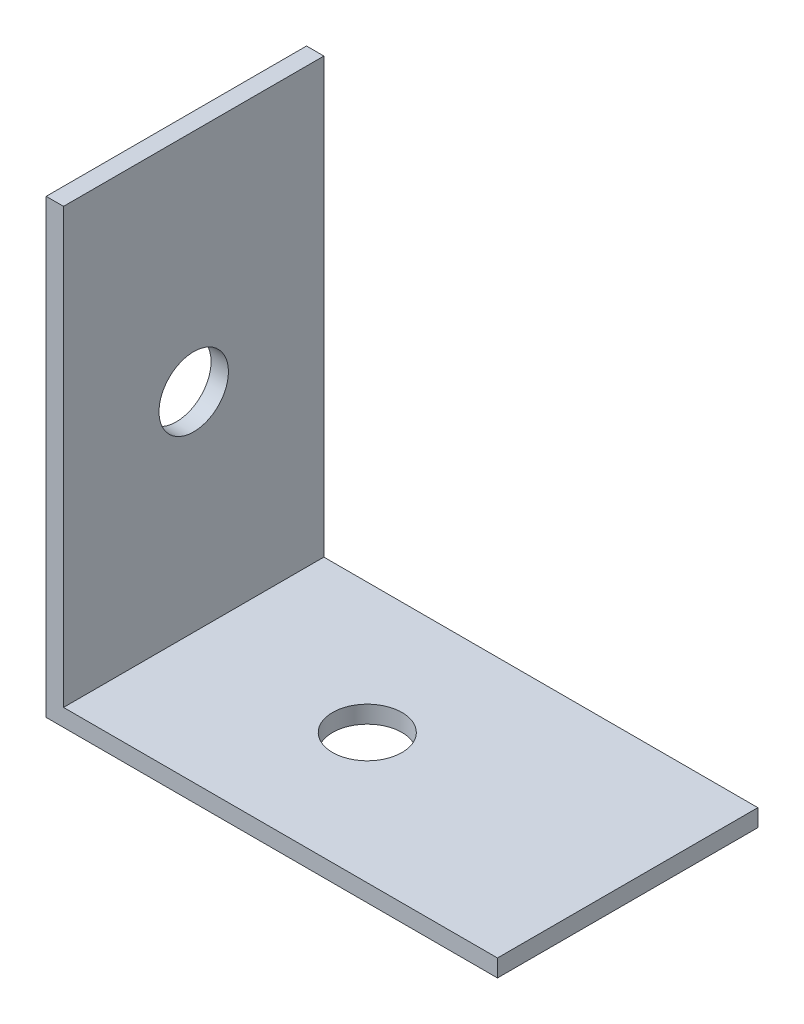
from build123d import *

# Parameters (mm, degrees)
RESSALTO_EXTRUS_O1_DEPTH = 15
ESBO_O2_R                = 2
CORTE_EXTRUS_O1_DEPTH    = 15
ESBO_O3_R                = 2
CORTE_EXTRUS_O2_DEPTH    = 10


with BuildPart() as part:
    # Esboço1 → Ressalto-extrusão1 (new body)
    with BuildSketch(Plane.XY):
        Polygon((0, 0), (25, 0), (25, -1), (-1, -1), (-1, 25), (0, 25), align=None)
    extrude(amount=RESSALTO_EXTRUS_O1_DEPTH)

    # Esboço2 → Corte-extrusão1 (cut)
    with BuildSketch(Plane(origin=(0, 0, 0), x_dir=(0, 0, -1), z_dir=(1, 0, 0))):
        with Locations((-7.5, 12)):
            Circle(ESBO_O2_R)
    extrude(amount=-CORTE_EXTRUS_O1_DEPTH, mode=Mode.SUBTRACT)

    # Esboço3 → Corte-extrusão2 (cut)
    with BuildSketch(Plane(origin=(0, 0, 0), x_dir=(1, 0, 0), z_dir=(0, 1, 0))):
        with Locations((10, -7.5)):
            Circle(ESBO_O3_R)
    extrude(amount=-CORTE_EXTRUS_O2_DEPTH, mode=Mode.SUBTRACT)


solid = part.part
